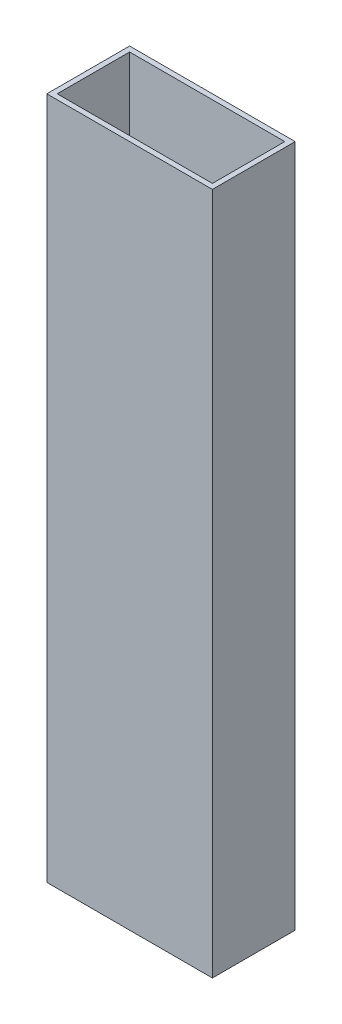
from build123d import *

# Parameters (mm, degrees)
SKETCH1_W           = 50.8
SKETCH1_H           = 25.4
SKETCH1_W_2         = 47.625
SKETCH1_H_2         = 22.225
BOSS_EXTRUDE1_DEPTH = 209.55


with BuildPart() as part:
    # Sketch1 → Boss-Extrude1 (new body)
    with BuildSketch(Plane(origin=(0, 0, 0), x_dir=(1, 0, 0), z_dir=(0, 1, 0))):
        with Locations((-4.778217822, 6.329042904)):
            Rectangle(SKETCH1_W, SKETCH1_H)
        with Locations((-4.778217822, 6.329042904)):
            Rectangle(SKETCH1_W_2, SKETCH1_H_2, mode=Mode.SUBTRACT)
    extrude(amount=BOSS_EXTRUDE1_DEPTH)


solid = part.part
